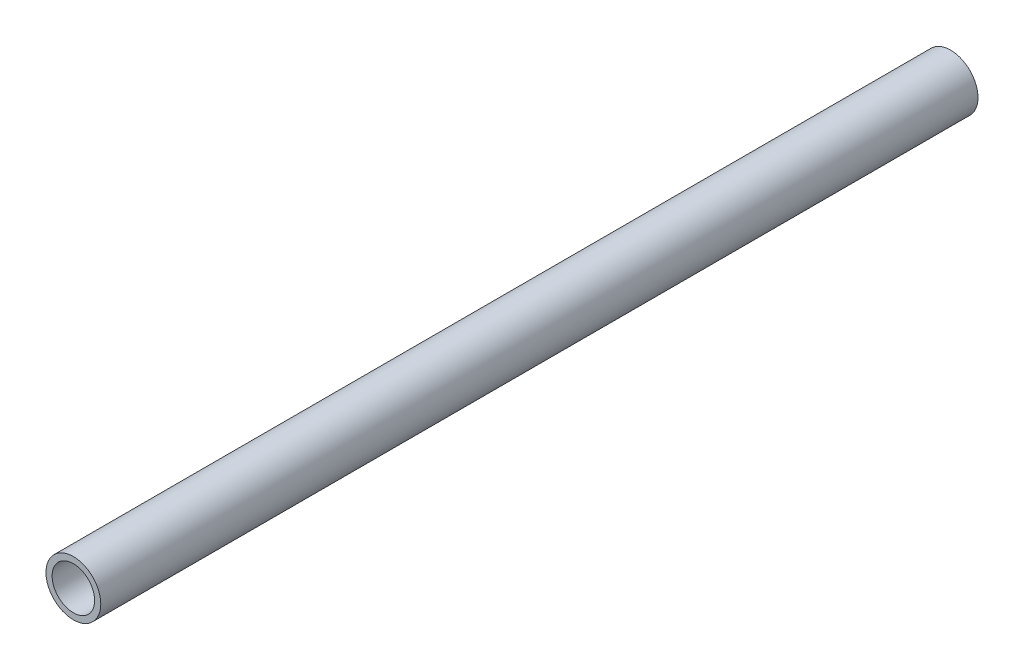
from build123d import *

# Parameters (mm, degrees)
SKETCH_1_R      = 12.5
SKETCH_1_R_2    = 9.7
EXTRUDE_1_DEPTH = 200


with BuildPart() as part:
    # 草图1 → 凸台-拉伸1 (new body, symmetric)
    with BuildSketch(Plane.XY):
        Circle(SKETCH_1_R)
        Circle(SKETCH_1_R_2, mode=Mode.SUBTRACT)
    extrude(amount=EXTRUDE_1_DEPTH, both=True)


solid = part.part
